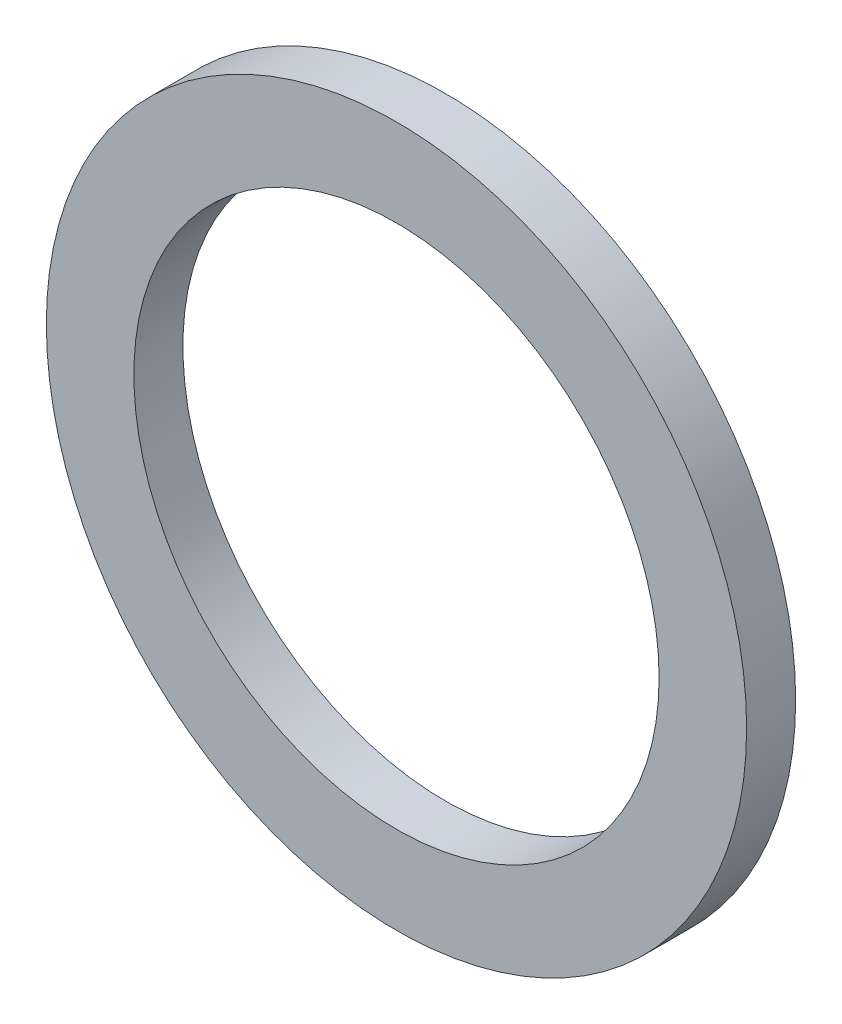
from build123d import *

# Parameters (mm, degrees)
SKETCH1_R           = 12.7
SKETCH1_R_2         = 9.525
BOSS_EXTRUDE1_DEPTH = 1.778


with BuildPart() as part:
    # Sketch1 → Boss-Extrude1 (new body)
    with BuildSketch(Plane.XY):
        Circle(SKETCH1_R)
        Circle(SKETCH1_R_2, mode=Mode.SUBTRACT)
    extrude(amount=BOSS_EXTRUDE1_DEPTH)


solid = part.part
